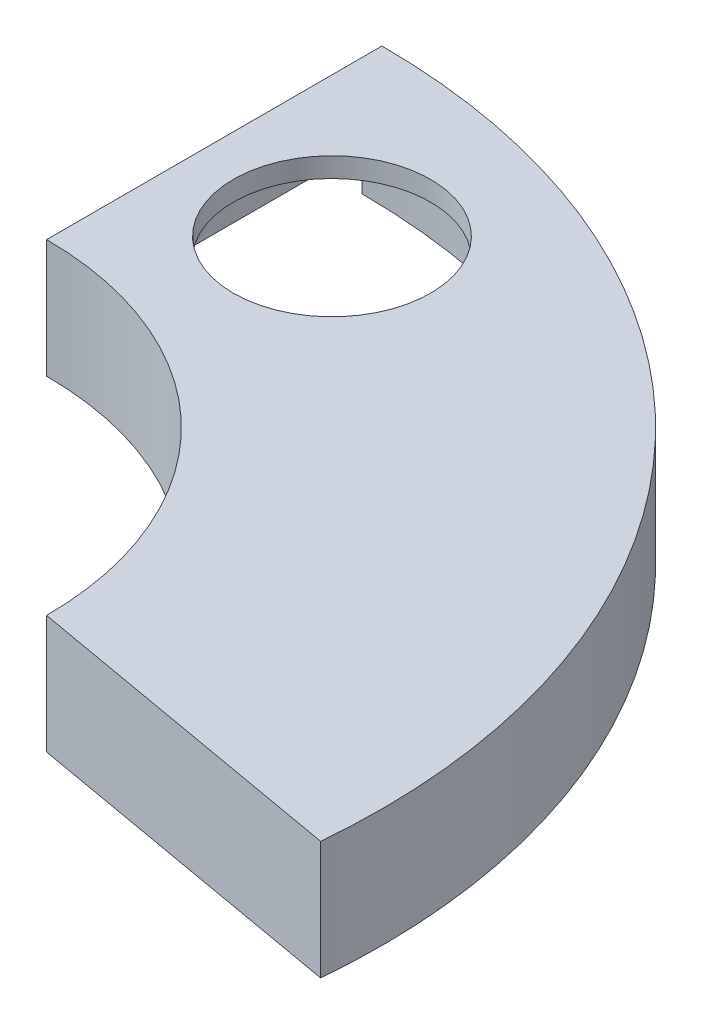
from build123d import *

# Parameters (mm, degrees)
CROQUIS1_R              = 50
SALIENTE_EXTRUIR1_DEPTH = 10
SALIENTE_EXTRUIR2_DEPTH = 50
CORTAR_EXTRUIR1_DEPTH   = 30


with BuildPart() as part:
    # Croquis1 → Saliente-Extruir1 (new body)
    with BuildSketch(Plane(origin=(0, 0, 0), x_dir=(1, 0, 0), z_dir=(0, 1, 0))):
        with BuildLine():
            Line((0, 165), (0, 335))
            ThreePointArc((0, 335), (247.172689972, 226.120899813), (333.677080988, -29.742320405))
            Line((333.677080988, -29.742320405), (165, 0))
            ThreePointArc((165, 0), (116.672618896, 116.672618896), (0, 165))
        make_face()
        with Locations((70.87743501, 238.796167173)):
            Circle(CROQUIS1_R, mode=Mode.SUBTRACT)
    extrude(amount=SALIENTE_EXTRUIR1_DEPTH)

    # Croquis2 → Saliente-Extruir2 (add)
    with BuildSketch(Plane.XZ):
        with BuildLine():
            Line((0, -165), (0, -335))
            ThreePointArc((0, -335), (247.172689972, -226.120899813), (333.677080988, 29.742320405))
            Line((333.677080988, 29.742320405), (165, 0))
            ThreePointArc((165, 0), (116.672618896, -116.672618896), (0, -165))
        make_face()
        with BuildLine():
            Line((10, -174.714052097), (10, -324.846117416))
            ThreePointArc((10, -324.846117416), (239.48657198, -219.707036394), (324.502797251, 17.970380535))
            Line((324.502797251, 17.970380535), (174.7969942, -8.426791712))
            ThreePointArc((174.7969942, -8.426791712), (124.299418776, -123.185447566), (10, -174.714052097))
        make_face(mode=Mode.SUBTRACT)
    extrude(amount=SALIENTE_EXTRUIR2_DEPTH)

    # Croquis3 → Cortar-Extruir1 (cut)
    with BuildSketch(Plane.XZ.offset(50)):
        with BuildLine():
            ThreePointArc((0, -325), (5.000591961, -324.961527077), (10, -324.846117416))
            Line((10, -324.846117416), (10, -174.714052097))
            ThreePointArc((10, -174.714052097), (5.002043737, -174.928498417), (0, -175))
            Line((0, -175), (0, -325))
        make_face()
    extrude(amount=-CORTAR_EXTRUIR1_DEPTH, mode=Mode.SUBTRACT)


solid = part.part
